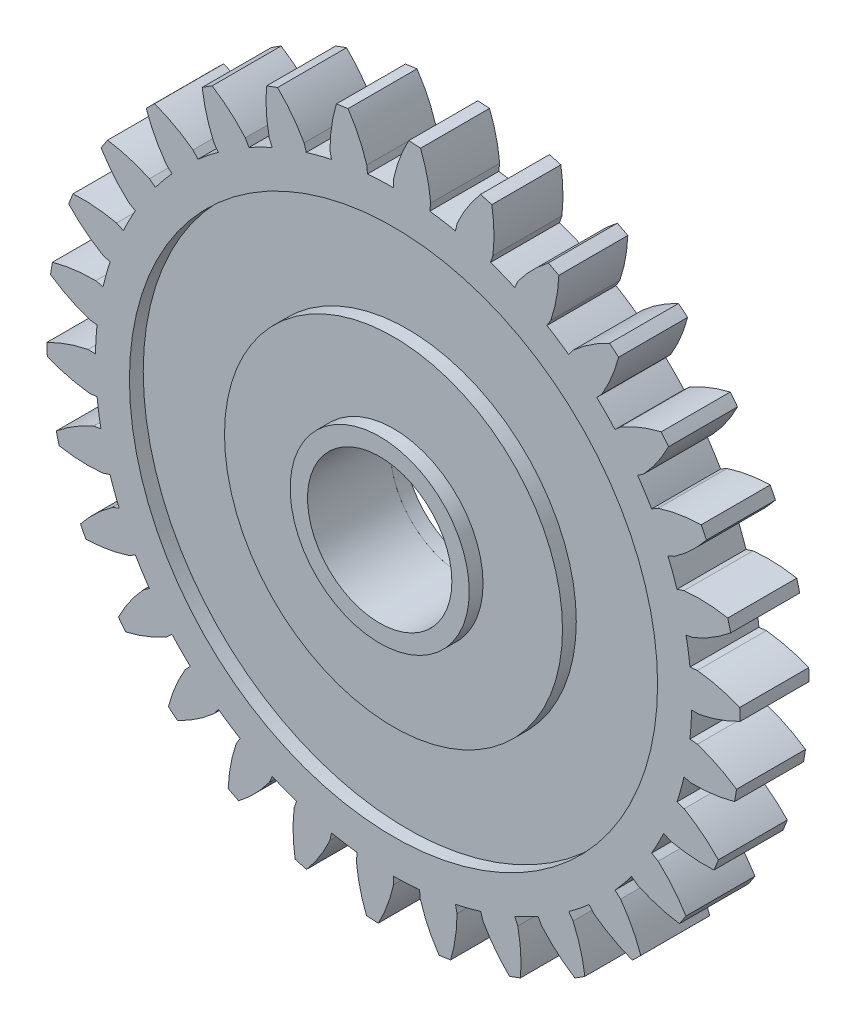
from build123d import *

# Parameters (mm, degrees)
BOSS_EXTRUDE1_DEPTH = 10
CIRPATTERN1_COUNT   = 30
SKETCH1_R           = 43.2025
BOSS_EXTRUDE2_DEPTH = 10
SKETCH4_R           = 38.277172717
SKETCH4_R_2         = 24.494404482
CUT_EXTRUDE1_DEPTH  = 2
SKETCH4_3_R         = 10.458579204
CUT_EXTRUDE2_DEPTH  = 72.748617782
BOSS_EXTRUDE3_START = 2
SKETCH4_4_R         = 12.980164355
SKETCH4_4_R_2       = 10.458579204
BOSS_EXTRUDE3_DEPTH = 2
CUT_EXTRUDE3_START  = -2
SKETCH5_R           = 38.277172717
SKETCH5_R_2         = 24.494404482
CUT_EXTRUDE3_DEPTH  = 2
SKETCH5_3_R         = 12.980164355
SKETCH5_3_R_2       = 10.458579204
BOSS_EXTRUDE4_DEPTH = 2


with BuildPart() as part:
    # Sketch3 → Boss-Extrude1 (new body)
    with BuildSketch(Plane.XY):
        with BuildLine():
            Line((5.25539159, 42.881661179), (5.387402942, 43.958815175))
            add(Edge.make_bspline(
                [(5.387402942, 43.958815175), (5.192603666, 46.126104526), (4.685094442, 48.17963563), (3.916971015, 50.119171203)],
                knots=[0, 0, 0, 0, 0.117304777, 0.117304777, 0.117304777, 0.117304777], degree=3))
            ThreePointArc((3.916971015, 50.119171203), (3.063375127, 50.178578266), (2.208891775, 50.223448519))
            add(Edge.make_bspline(
                [(0, 44.287713218), (0.45699371, 46.415210959), (1.210536877, 48.391755495), (2.208891775, 50.223448519)],
                knots=[0, 0, 0, 0, 0.117304777, 0.117304777, 0.117304777, 0.117304777], degree=3))
            Line((0, 44.287713218), (0, 43.2025))
            ThreePointArc((0, 43.2025), (2.632588, 43.122215698), (5.25539159, 42.881661179))
        make_face()
    extrude(amount=BOSS_EXTRUDE1_DEPTH)


with BuildPart() as cirpattern1_1:
    # CirPattern1: pattern copy
    add(part.part.rotate(Axis((0, 0, 0), (0, 0, 1)), 1 * 360 / CIRPATTERN1_COUNT))


with BuildPart() as cirpattern1_2:
    # CirPattern1: pattern copy
    add(part.part.rotate(Axis((0, 0, 0), (0, 0, 1)), 2 * 360 / CIRPATTERN1_COUNT))


with BuildPart() as cirpattern1_3:
    # CirPattern1: pattern copy
    add(part.part.rotate(Axis((0, 0, 0), (0, 0, 1)), 3 * 360 / CIRPATTERN1_COUNT))


with BuildPart() as cirpattern1_4:
    # CirPattern1: pattern copy
    add(part.part.rotate(Axis((0, 0, 0), (0, 0, 1)), 4 * 360 / CIRPATTERN1_COUNT))


with BuildPart() as cirpattern1_5:
    # CirPattern1: pattern copy
    add(part.part.rotate(Axis((0, 0, 0), (0, 0, 1)), 5 * 360 / CIRPATTERN1_COUNT))


with BuildPart() as cirpattern1_6:
    # CirPattern1: pattern copy
    add(part.part.rotate(Axis((0, 0, 0), (0, 0, 1)), 6 * 360 / CIRPATTERN1_COUNT))


with BuildPart() as cirpattern1_7:
    # CirPattern1: pattern copy
    add(part.part.rotate(Axis((0, 0, 0), (0, 0, 1)), 7 * 360 / CIRPATTERN1_COUNT))


with BuildPart() as cirpattern1_8:
    # CirPattern1: pattern copy
    add(part.part.rotate(Axis((0, 0, 0), (0, 0, 1)), 8 * 360 / CIRPATTERN1_COUNT))


with BuildPart() as cirpattern1_9:
    # CirPattern1: pattern copy
    add(part.part.rotate(Axis((0, 0, 0), (0, 0, 1)), 9 * 360 / CIRPATTERN1_COUNT))


with BuildPart() as cirpattern1_10:
    # CirPattern1: pattern copy
    add(part.part.rotate(Axis((0, 0, 0), (0, 0, 1)), 10 * 360 / CIRPATTERN1_COUNT))


with BuildPart() as cirpattern1_11:
    # CirPattern1: pattern copy
    add(part.part.rotate(Axis((0, 0, 0), (0, 0, 1)), 11 * 360 / CIRPATTERN1_COUNT))


with BuildPart() as cirpattern1_12:
    # CirPattern1: pattern copy
    add(part.part.rotate(Axis((0, 0, 0), (0, 0, 1)), 12 * 360 / CIRPATTERN1_COUNT))


with BuildPart() as cirpattern1_13:
    # CirPattern1: pattern copy
    add(part.part.rotate(Axis((0, 0, 0), (0, 0, 1)), 13 * 360 / CIRPATTERN1_COUNT))


with BuildPart() as cirpattern1_14:
    # CirPattern1: pattern copy
    add(part.part.rotate(Axis((0, 0, 0), (0, 0, 1)), 14 * 360 / CIRPATTERN1_COUNT))


with BuildPart() as cirpattern1_15:
    # CirPattern1: pattern copy
    add(part.part.rotate(Axis((0, 0, 0), (0, 0, 1)), 15 * 360 / CIRPATTERN1_COUNT))


with BuildPart() as cirpattern1_16:
    # CirPattern1: pattern copy
    add(part.part.rotate(Axis((0, 0, 0), (0, 0, 1)), 16 * 360 / CIRPATTERN1_COUNT))


with BuildPart() as cirpattern1_17:
    # CirPattern1: pattern copy
    add(part.part.rotate(Axis((0, 0, 0), (0, 0, 1)), 17 * 360 / CIRPATTERN1_COUNT))


with BuildPart() as cirpattern1_18:
    # CirPattern1: pattern copy
    add(part.part.rotate(Axis((0, 0, 0), (0, 0, 1)), 18 * 360 / CIRPATTERN1_COUNT))


with BuildPart() as cirpattern1_19:
    # CirPattern1: pattern copy
    add(part.part.rotate(Axis((0, 0, 0), (0, 0, 1)), 19 * 360 / CIRPATTERN1_COUNT))


with BuildPart() as cirpattern1_20:
    # CirPattern1: pattern copy
    add(part.part.rotate(Axis((0, 0, 0), (0, 0, 1)), 20 * 360 / CIRPATTERN1_COUNT))


with BuildPart() as cirpattern1_21:
    # CirPattern1: pattern copy
    add(part.part.rotate(Axis((0, 0, 0), (0, 0, 1)), 21 * 360 / CIRPATTERN1_COUNT))


with BuildPart() as cirpattern1_22:
    # CirPattern1: pattern copy
    add(part.part.rotate(Axis((0, 0, 0), (0, 0, 1)), 22 * 360 / CIRPATTERN1_COUNT))


with BuildPart() as cirpattern1_23:
    # CirPattern1: pattern copy
    add(part.part.rotate(Axis((0, 0, 0), (0, 0, 1)), 23 * 360 / CIRPATTERN1_COUNT))


with BuildPart() as cirpattern1_24:
    # CirPattern1: pattern copy
    add(part.part.rotate(Axis((0, 0, 0), (0, 0, 1)), 24 * 360 / CIRPATTERN1_COUNT))


with BuildPart() as cirpattern1_25:
    # CirPattern1: pattern copy
    add(part.part.rotate(Axis((0, 0, 0), (0, 0, 1)), 25 * 360 / CIRPATTERN1_COUNT))


with BuildPart() as cirpattern1_26:
    # CirPattern1: pattern copy
    add(part.part.rotate(Axis((0, 0, 0), (0, 0, 1)), 26 * 360 / CIRPATTERN1_COUNT))


with BuildPart() as cirpattern1_27:
    # CirPattern1: pattern copy
    add(part.part.rotate(Axis((0, 0, 0), (0, 0, 1)), 27 * 360 / CIRPATTERN1_COUNT))


with BuildPart() as cirpattern1_28:
    # CirPattern1: pattern copy
    add(part.part.rotate(Axis((0, 0, 0), (0, 0, 1)), 28 * 360 / CIRPATTERN1_COUNT))


with BuildPart() as cirpattern1_29:
    # CirPattern1: pattern copy
    add(part.part.rotate(Axis((0, 0, 0), (0, 0, 1)), 29 * 360 / CIRPATTERN1_COUNT))


with BuildPart() as part_1:
    add(part.part)

    add(cirpattern1_1.part)  # Boss-Extrude2 merges CirPattern1_1

    add(cirpattern1_2.part)  # Boss-Extrude2 merges CirPattern1_2

    add(cirpattern1_3.part)  # Boss-Extrude2 merges CirPattern1_3

    add(cirpattern1_4.part)  # Boss-Extrude2 merges CirPattern1_4

    add(cirpattern1_5.part)  # Boss-Extrude2 merges CirPattern1_5

    add(cirpattern1_6.part)  # Boss-Extrude2 merges CirPattern1_6

    add(cirpattern1_7.part)  # Boss-Extrude2 merges CirPattern1_7

    add(cirpattern1_8.part)  # Boss-Extrude2 merges CirPattern1_8

    add(cirpattern1_9.part)  # Boss-Extrude2 merges CirPattern1_9

    add(cirpattern1_10.part)  # Boss-Extrude2 merges CirPattern1_10

    add(cirpattern1_11.part)  # Boss-Extrude2 merges CirPattern1_11

    add(cirpattern1_12.part)  # Boss-Extrude2 merges CirPattern1_12

    add(cirpattern1_13.part)  # Boss-Extrude2 merges CirPattern1_13

    add(cirpattern1_14.part)  # Boss-Extrude2 merges CirPattern1_14

    add(cirpattern1_15.part)  # Boss-Extrude2 merges CirPattern1_15

    add(cirpattern1_16.part)  # Boss-Extrude2 merges CirPattern1_16

    add(cirpattern1_17.part)  # Boss-Extrude2 merges CirPattern1_17

    add(cirpattern1_18.part)  # Boss-Extrude2 merges CirPattern1_18

    add(cirpattern1_19.part)  # Boss-Extrude2 merges CirPattern1_19

    add(cirpattern1_20.part)  # Boss-Extrude2 merges CirPattern1_20

    add(cirpattern1_21.part)  # Boss-Extrude2 merges CirPattern1_21

    add(cirpattern1_22.part)  # Boss-Extrude2 merges CirPattern1_22

    add(cirpattern1_23.part)  # Boss-Extrude2 merges CirPattern1_23

    add(cirpattern1_24.part)  # Boss-Extrude2 merges CirPattern1_24

    add(cirpattern1_25.part)  # Boss-Extrude2 merges CirPattern1_25

    add(cirpattern1_26.part)  # Boss-Extrude2 merges CirPattern1_26

    add(cirpattern1_27.part)  # Boss-Extrude2 merges CirPattern1_27

    add(cirpattern1_28.part)  # Boss-Extrude2 merges CirPattern1_28

    add(cirpattern1_29.part)  # Boss-Extrude2 merges CirPattern1_29
    # Sketch1 → Boss-Extrude2 (add)
    with BuildSketch(Plane.XY):
        Circle(SKETCH1_R)
    extrude(amount=BOSS_EXTRUDE2_DEPTH)

    # Sketch4 → Cut-Extrude1 (cut)
    with BuildSketch(Plane.XY.offset(10)):
        Circle(SKETCH4_R)
        Circle(SKETCH4_R_2, mode=Mode.SUBTRACT)
    extrude(amount=-CUT_EXTRUDE1_DEPTH, mode=Mode.SUBTRACT)

    # Sketch4_3 → Cut-Extrude2 (cut, through all)
    with BuildSketch(Plane.XY.offset(10)):
        Circle(SKETCH4_3_R)
    extrude(amount=-CUT_EXTRUDE2_DEPTH, mode=Mode.SUBTRACT)

    # Sketch4_4 → Boss-Extrude3 (add)
    with BuildSketch(Plane.XY.offset(10).offset(BOSS_EXTRUDE3_START)):
        Circle(SKETCH4_4_R)
        Circle(SKETCH4_4_R_2, mode=Mode.SUBTRACT)
    extrude(amount=-BOSS_EXTRUDE3_DEPTH)

    # Sketch5 → Cut-Extrude3 (cut)
    with BuildSketch(Plane(origin=(0, 0, 0), x_dir=(-1, 0, 0), z_dir=(0, 0, -1)).offset(CUT_EXTRUDE3_START)):
        Circle(SKETCH5_R)
        Circle(SKETCH5_R_2, mode=Mode.SUBTRACT)
    extrude(amount=CUT_EXTRUDE3_DEPTH, mode=Mode.SUBTRACT)


with BuildPart() as body_2:
    # Sketch5_3 → Boss-Extrude4 (new body)
    with BuildSketch(Plane(origin=(0, 0, 0), x_dir=(-1, 0, 0), z_dir=(0, 0, -1))):
        Circle(SKETCH5_3_R)
        Circle(SKETCH5_3_R_2, mode=Mode.SUBTRACT)
    extrude(amount=BOSS_EXTRUDE4_DEPTH)


solid = Compound([part_1.part, body_2.part])
